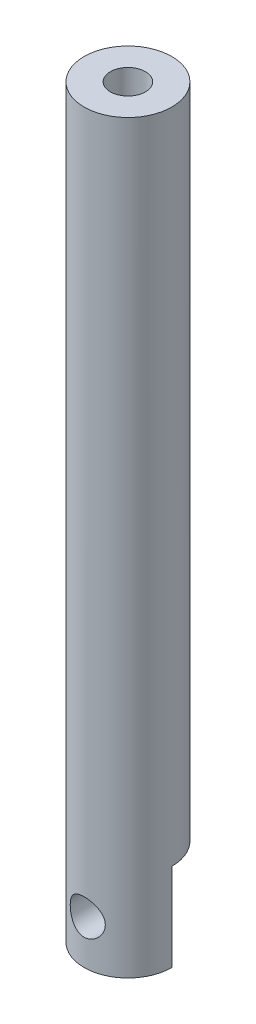
from build123d import *

# Parameters (mm, degrees)
SKETCH1_R           = 5
BOSS_EXTRUDE1_DEPTH = 85
SKETCH2_R           = 2
CUT_EXTRUDE1_DEPTH  = 15
CUT_EXTRUDE5_DEPTH  = 10
SKETCH6_R           = 2
CUT_EXTRUDE6_DEPTH  = 6


with BuildPart() as part:
    # Sketch1 → Boss-Extrude1 (new body)
    with BuildSketch(Plane(origin=(0, 0, 0), x_dir=(1, 0, 0), z_dir=(0, 1, 0))):
        Circle(SKETCH1_R)
    extrude(amount=BOSS_EXTRUDE1_DEPTH)

    # Sketch2 → Cut-Extrude1 (cut)
    with BuildSketch(Plane(origin=(0, 85, 0), x_dir=(1, 0, 0), z_dir=(0, 1, 0))):
        Circle(SKETCH2_R)
    extrude(amount=-CUT_EXTRUDE1_DEPTH, mode=Mode.SUBTRACT)

    # Sketch3 → Cut-Extrude5 (cut)
    with BuildSketch(Plane.XZ):
        with BuildLine():
            Line((5, 0), (-5, 0))
            ThreePointArc((-5, 0), (0, -5), (5, 0))
        make_face()
    extrude(amount=-CUT_EXTRUDE5_DEPTH, mode=Mode.SUBTRACT)

    # Sketch6 → Cut-Extrude6 (cut, through all)
    with BuildSketch(Plane(origin=(0, 0, 0), x_dir=(-1, 0, 0), z_dir=(0, 0, -1))):
        with Locations((0, 5)):
            Circle(SKETCH6_R)
    extrude(amount=-CUT_EXTRUDE6_DEPTH, mode=Mode.SUBTRACT)


solid = part.part
